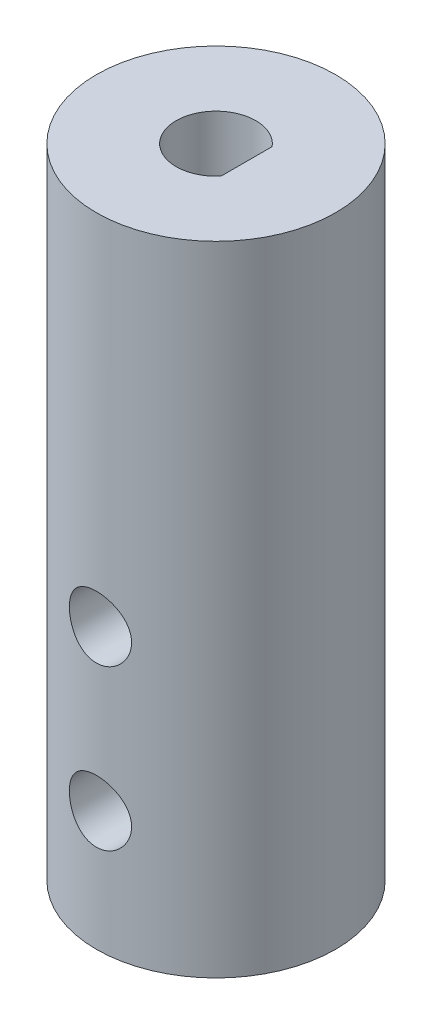
from build123d import *

# Parameters (mm, degrees)
SKETCH1_R           = 9.525
BOSS_EXTRUDE1_DEPTH = 50.8
SKETCH2_R           = 2.4765
CUT_EXTRUDE1_DEPTH  = 20.05


with BuildPart() as part:
    # Sketch1 → Boss-Extrude1 (new body)
    with BuildSketch(Plane(origin=(0, 0, 0), x_dir=(1, 0, 0), z_dir=(0, 1, 0))):
        Circle(SKETCH1_R)
        with BuildLine():
            Line((2.439590334, 2.032), (2.439590334, -2.032))
            ThreePointArc((2.439590334, -2.032), (-3.175, 0), (2.439590334, 2.032))
        make_face(mode=Mode.SUBTRACT)
    extrude(amount=BOSS_EXTRUDE1_DEPTH)

    # Sketch2 → Cut-Extrude1 (cut, through all)
    with BuildSketch(Plane.XY.offset(9.525)):
        with Locations((0, 9.525)):
            Circle(SKETCH2_R)
        with Locations((0, 22.225)):
            Circle(SKETCH2_R)
    extrude(amount=-CUT_EXTRUDE1_DEPTH, mode=Mode.SUBTRACT)


solid = part.part
